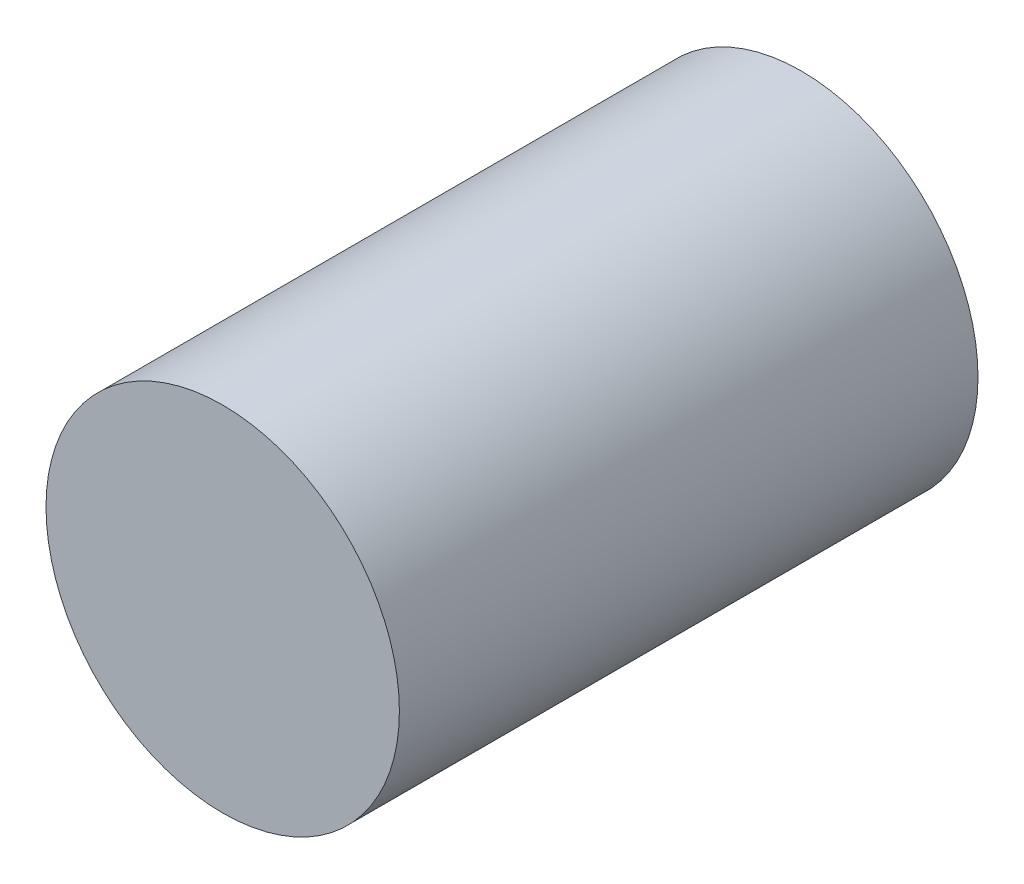
from build123d import *

# Parameters (mm, degrees)
SKIZZE1_R                       = 28.4
AUFSATZ_LINEAR_AUSTRAGEN1_DEPTH = 93


with BuildPart() as part:
    # Skizze1 → Aufsatz-Linear austragen1 (new body)
    with BuildSketch(Plane.XY):
        Circle(SKIZZE1_R)
    extrude(amount=AUFSATZ_LINEAR_AUSTRAGEN1_DEPTH)


solid = part.part
